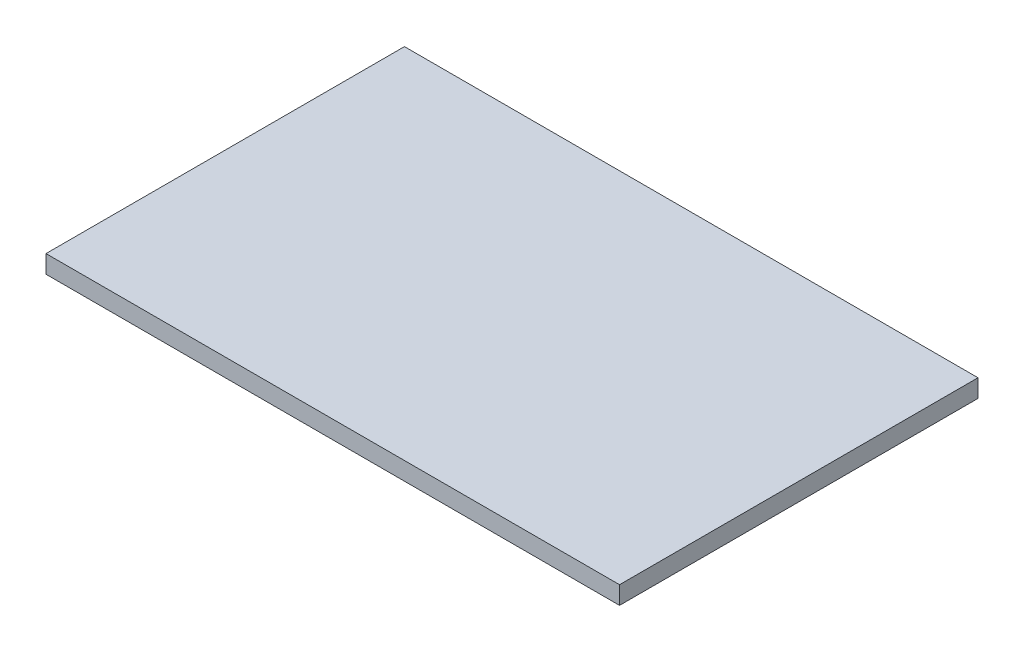
from build123d import *

# Parameters (mm, degrees)
SKETCH1_W           = 160
SKETCH1_H           = 100
BOSS_EXTRUDE1_DEPTH = 5


with BuildPart() as part:
    # Sketch1 → Boss-Extrude1 (new body)
    with BuildSketch(Plane(origin=(0, 0, 0), x_dir=(1, 0, 0), z_dir=(0, 1, 0))):
        with Locations((32.600005306, 29.333277951)):
            Rectangle(SKETCH1_W, SKETCH1_H)
    extrude(amount=BOSS_EXTRUDE1_DEPTH)


solid = part.part
